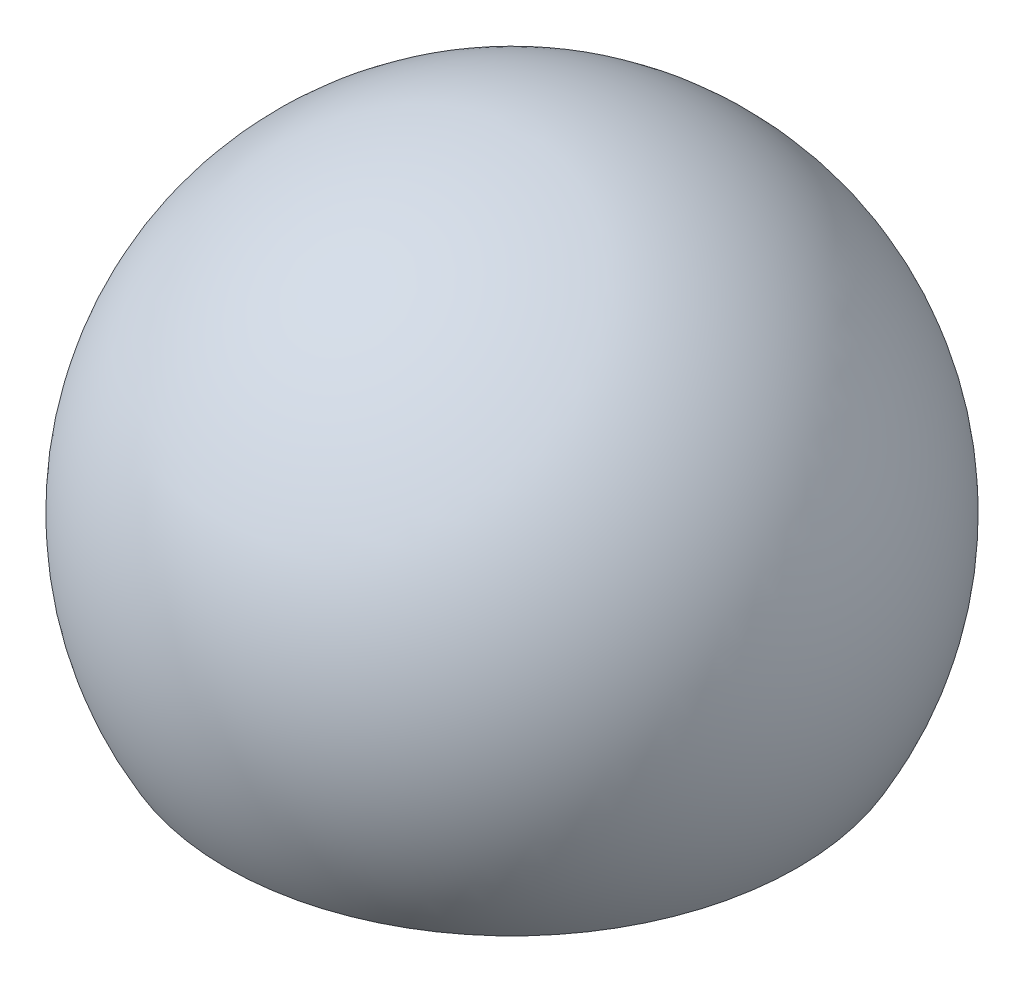
from build123d import *

# Parameters (mm, degrees)
TRUNCATED_BALL_DEPTH      = 13.7
TRUNCATED_BALL_DEPTH_BACK = 13.7
SKETCH3_R                 = 8.4582
RECESSED_DEPTH            = 0.127


with BuildPart() as part:
    # Sketch1 → Complete_Ball (revolve)
    with BuildSketch(Plane.XY):
        with BuildLine():
            Line((0, 12.7), (0, -12.7))
            ThreePointArc((0, -12.7), (12.7, 0), (0, 12.7))
        make_face()
    revolve(axis=Axis((0, 13.6525, 0), (0, -1, 0)))

    # Sketch2 → Truncated_ball (cut, two sides)
    with BuildSketch(Plane.XY) as truncated_ball_sk:
        with BuildLine():
            Line((-10.998522628, -6.35), (10.998522628, -6.35))
            ThreePointArc((10.998522628, -6.35), (0, -12.7), (-10.998522628, -6.35))
        make_face()
    extrude(amount=TRUNCATED_BALL_DEPTH, mode=Mode.SUBTRACT)
    extrude(truncated_ball_sk.sketch, amount=-TRUNCATED_BALL_DEPTH_BACK, mode=Mode.SUBTRACT)

    # Sketch3 → Recessed (cut)
    with BuildSketch(Plane.XZ.offset(6.35)):
        with Locations(Location((0, 0, 0), (0, 0, 270))):  # turned: the seam where the file's is
            Circle(SKETCH3_R)
    extrude(amount=-RECESSED_DEPTH, mode=Mode.SUBTRACT)


solid = part.part
